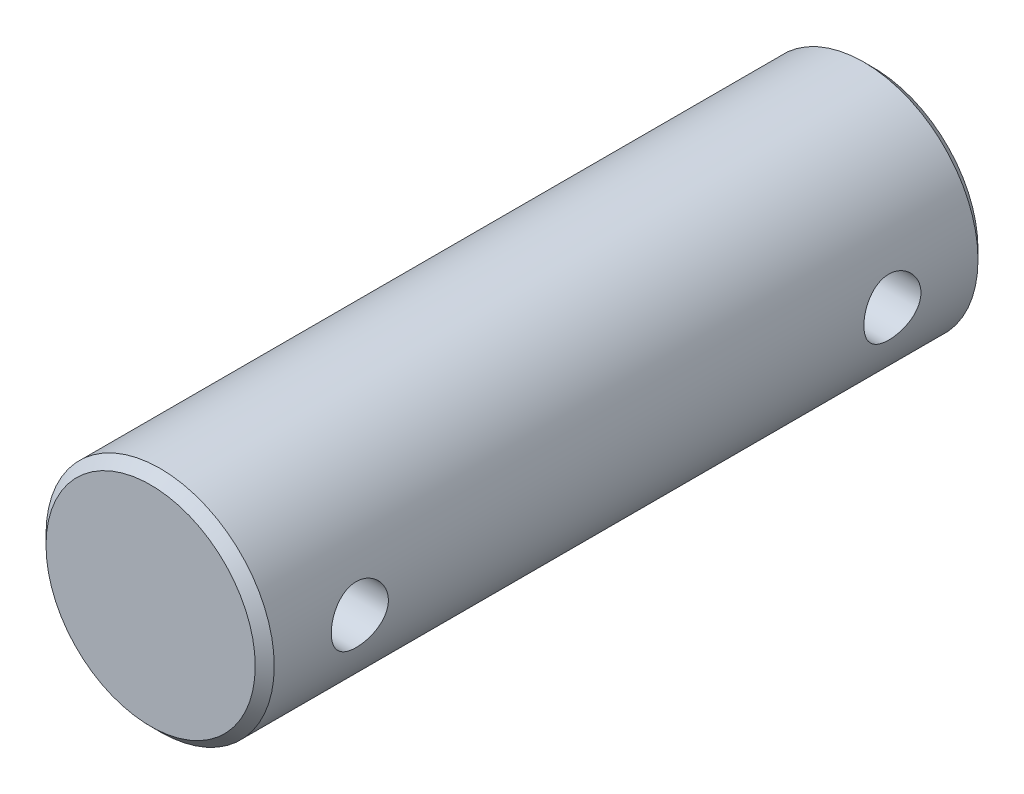
from build123d import *

# Parameters (mm, degrees)
SKETCH1_R               = 6
BOSS_EXTRUDE1_DEPTH     = 38
CHAMFER1_SIZE           = 0.5
SKETCH2_R               = 1.5
CUT_EXTRUDE1_DEPTH      = 7
CUT_EXTRUDE1_DEPTH_BACK = 7


with BuildPart() as part:
    # Sketch1 → Boss-Extrude1 (new body)
    with BuildSketch(Plane.XY):
        Circle(SKETCH1_R)
    extrude(amount=-BOSS_EXTRUDE1_DEPTH)

    # Chamfer1
    chamfer1_edges = [part.edges().sort_by_distance(p)[0] for p in [
        (-6, 0, 0),
        (-6, 0, -38),
    ]]
    chamfer(chamfer1_edges, length=CHAMFER1_SIZE)

    # Sketch2 → Cut-Extrude1 (cut, two sides)
    with BuildSketch(Plane(origin=(0, 0, 0), x_dir=(0, 0, -1), z_dir=(1, 0, 0))) as cut_extrude1_sk:
        with Locations((5, 0)):
            Circle(SKETCH2_R)
        with Locations((33, 0)):
            Circle(SKETCH2_R)
    extrude(amount=CUT_EXTRUDE1_DEPTH, mode=Mode.SUBTRACT)
    extrude(cut_extrude1_sk.sketch, amount=-CUT_EXTRUDE1_DEPTH_BACK, mode=Mode.SUBTRACT)


solid = part.part
